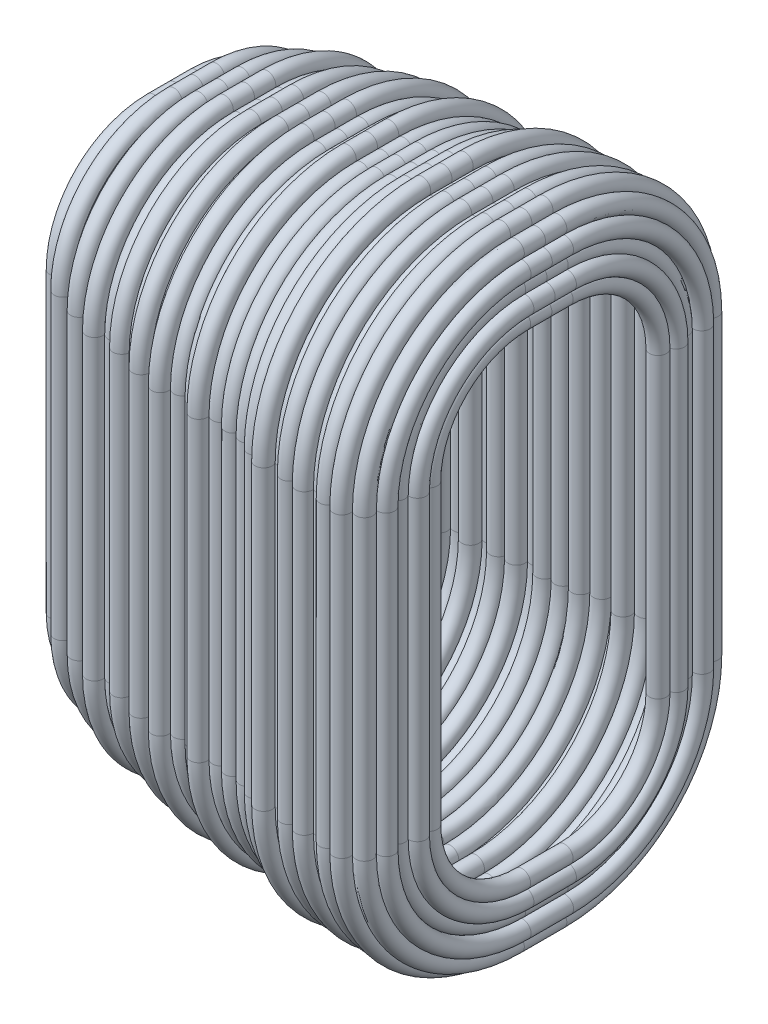
from build123d import *


with BuildPart() as part:
    # Barrer1: sweep along a path in Croquis1
    with BuildLine(Plane(origin=(0, 0, 0), x_dir=(0, 0, -1), z_dir=(1, 0, 0))) as barrer1_path:
        Line((-0.25, 2.55), (0.25, 2.55))
        ThreePointArc((0.25, 2.55), (0.815685425, 2.315685425), (1.05, 1.75))
        Line((1.05, 1.75), (1.05, -1.75))
        ThreePointArc((1.05, -1.75), (0.815685425, -2.315685425), (0.25, -2.55))
        Line((0.25, -2.55), (-0.25, -2.55))
        ThreePointArc((-0.25, -2.55), (-0.815685425, -2.315685425), (-1.05, -1.75))
        Line((-1.05, -1.75), (-1.05, 1.75))
        ThreePointArc((-1.05, 1.75), (-0.815685425, 2.315685425), (-0.25, 2.55))
    # Croquis2 → Barrer1 (sweep)
    with BuildSketch(Plane.XY):
        with BuildLine():
            ThreePointArc((-2.168358999, 2.810721498), (-2.293450616, 2.701666902), (-2.145279967, 2.626925508))
            ThreePointArc((-2.145279967, 2.626925508), (-2.00206537, 2.488675521), (-2.115884149, 2.651981262))
            ThreePointArc((-2.115884149, 2.651981262), (-2.094230788, 2.714572804), (-2.116442681, 2.776968325))
            ThreePointArc((-2.116442681, 2.776968325), (-2.043783884, 2.785184688), (-1.996141742, 2.840655723))
            ThreePointArc((-1.996141742, 2.840655723), (-1.840039556, 2.796265073), (-1.847409239, 2.958388822))
            ThreePointArc((-1.847409239, 2.958388822), (-1.800657274, 2.972997965), (-1.766451452, 3.008056987))
            ThreePointArc((-1.766451452, 3.008056987), (-1.632539652, 2.921291995), (-1.585632666, 3.07380517))
            ThreePointArc((-1.585632666, 3.07380517), (-1.515452014, 3.073795574), (-1.462548178, 3.119909652))
            ThreePointArc((-1.462548178, 3.119909652), (-1.326912178, 3.031556502), (-1.284986756, 3.187907591))
            ThreePointArc((-1.284986756, 3.187907591), (-1.230944112, 3.185886052), (-1.183751847, 3.212297872))
            ThreePointArc((-1.183751847, 3.212297872), (-1.082680639, 3.090059437), (-0.990641083, 3.219235069))
            ThreePointArc((-0.990641083, 3.219235069), (-0.906566815, 3.196111267), (-0.836308297, 3.247753627))
            ThreePointArc((-0.836308297, 3.247753627), (-0.709225872, 3.156781549), (-0.648631696, 3.300844756))
            ThreePointArc((-0.648631696, 3.300844756), (-0.58323563, 3.290594778), (-0.525764362, 3.323439273))
            ThreePointArc((-0.525764362, 3.323439273), (-0.404715905, 3.2142119), (-0.341420805, 3.364468607))
            ThreePointArc((-0.341420805, 3.364468607), (-0.288510223, 3.359265806), (-0.240410905, 3.381916512))
            ThreePointArc((-0.240410905, 3.381916512), (-0.162710771, 3.26234603), (-0.044456194, 3.342034585))
            ThreePointArc((-0.044456194, 3.342034585), (0.085569109, 3.287089434), (0.140997905, 3.4169093))
            ThreePointArc((0.140997905, 3.4169093), (0.200954751, 3.402705221), (0.25785639, 3.426343804))
            ThreePointArc((0.25785639, 3.426343804), (0.334921236, 3.307268755), (0.453540083, 3.385033957))
            ThreePointArc((0.453540083, 3.385033957), (0.552592446, 3.341279753), (0.633405604, 3.41335634))
            ThreePointArc((0.633405604, 3.41335634), (0.751330258, 3.358801429), (0.823600044, 3.466780782))
            ThreePointArc((0.823600044, 3.466780782), (0.940020945, 3.441687637), (0.997887622, 3.545778654))
            ThreePointArc((0.997887622, 3.545778654), (1.052489374, 3.517501776), (1.113313954, 3.526518624))
            ThreePointArc((1.113313954, 3.526518624), (1.200440747, 3.37919275), (1.290388928, 3.524813202))
            ThreePointArc((1.290388928, 3.524813202), (1.394523226, 3.508426363), (1.455477998, 3.594432157))
            ThreePointArc((1.455477998, 3.594432157), (1.512862487, 3.529068305), (1.59973518, 3.533375056))
            ThreePointArc((1.59973518, 3.533375056), (1.692021184, 3.425750606), (1.799184117, 3.518572126))
            ThreePointArc((1.799184117, 3.518572126), (1.874502079, 3.526382707), (1.922753097, 3.584740568))
            ThreePointArc((1.922753097, 3.584740568), (1.993034437, 3.537521837), (2.074343916, 3.561140555))
            ThreePointArc((2.074343916, 3.561140555), (2.0938295, 3.466882407), (2.183816439, 3.432726333))
            ThreePointArc((2.183816439, 3.432726333), (2.150391968, 3.343546059), (2.206811777, 3.266818478))
            ThreePointArc((2.206811777, 3.266818478), (2.086721351, 3.174527912), (2.19565867, 3.069304722))
            ThreePointArc((2.19565867, 3.069304722), (2.184676162, 3.003257127), (2.217825502, 2.945084782))
            ThreePointArc((2.217825502, 2.945084782), (2.22202767, 2.751072709), (2.309411763, 2.924342334))
            ThreePointArc((2.309411763, 2.924342334), (2.381531029, 3.038585903), (2.27402465, 3.120409861))
            ThreePointArc((2.27402465, 3.120409861), (2.28173102, 3.199597068), (2.229195574, 3.259346786))
            ThreePointArc((2.229195574, 3.259346786), (2.349392911, 3.354046352), (2.235558255, 3.456306211))
            ThreePointArc((2.235558255, 3.456306211), (2.245250912, 3.597535132), (2.104003097, 3.606948449))
            ThreePointArc((2.104003097, 3.606948449), (2.038008411, 3.73185315), (1.912960411, 3.666130395))
            ThreePointArc((1.912960411, 3.666130395), (1.803867308, 3.711756098), (1.727534764, 3.62144357))
            ThreePointArc((1.727534764, 3.62144357), (1.688718417, 3.624901751), (1.651527701, 3.613260511))
            ThreePointArc((1.651527701, 3.613260511), (1.558857893, 3.720912704), (1.452028583, 3.62729547))
            ThreePointArc((1.452028583, 3.62729547), (1.319302795, 3.693722469), (1.266681323, 3.554943286))
            ThreePointArc((1.266681323, 3.554943286), (1.213948769, 3.578398112), (1.157037676, 3.568807564))
            ThreePointArc((1.157037676, 3.568807564), (1.086976961, 3.7144994), (0.969797781, 3.603127704))
            ThreePointArc((0.969797781, 3.603127704), (0.855341676, 3.622861541), (0.799425019, 3.521062956))
            ThreePointArc((0.799425019, 3.521062956), (0.701961791, 3.55255142), (0.62791956, 3.481781708))
            ThreePointArc((0.62791956, 3.481781708), (0.525652678, 3.539412387), (0.439074118, 3.460140935))
            ThreePointArc((0.439074118, 3.460140935), (0.3695891, 3.50412567), (0.290627618, 3.481149399))
            ThreePointArc((0.290627618, 3.481149399), (0.184614129, 3.60203641), (0.100041078, 3.465288729))
            ThreePointArc((0.100041078, 3.465288729), (0.007312491, 3.471106825), (-0.050179333, 3.398119626))
            ThreePointArc((-0.050179333, 3.398119626), (-0.119279715, 3.45753969), (-0.207887728, 3.436227093))
            ThreePointArc((-0.207887728, 3.436227093), (-0.322297889, 3.556390961), (-0.390552102, 3.405161326))
            ThreePointArc((-0.390552102, 3.405161326), (-0.450670194, 3.408843826), (-0.501998657, 3.377329786))
            ThreePointArc((-0.501998657, 3.377329786), (-0.620325537, 3.487123317), (-0.689136333, 3.341106386))
            ThreePointArc((-0.689136333, 3.341106386), (-0.765624381, 3.348654019), (-0.824875806, 3.299698356))
            ThreePointArc((-0.824875806, 3.299698356), (-0.942113133, 3.392925406), (-1.020367381, 3.265206392))
            ThreePointArc((-1.020367381, 3.265206392), (-1.08949567, 3.289942958), (-1.156885482, 3.260801384))
            ThreePointArc((-1.156885482, 3.260801384), (-1.276978286, 3.380514314), (-1.332054835, 3.220139625))
            ThreePointArc((-1.332054835, 3.220139625), (-1.399965168, 3.217729992), (-1.450656286, 3.172474825))
            ThreePointArc((-1.450656286, 3.172474825), (-1.583672784, 3.261789437), (-1.631608946, 3.108908395))
            ThreePointArc((-1.631608946, 3.108908395), (-1.700365438, 3.109439167), (-1.753211505, 3.065450191))
            ThreePointArc((-1.753211505, 3.065450191), (-1.90368865, 3.144407534), (-1.90764713, 2.974519443))
            ThreePointArc((-1.90764713, 2.974519443), (-1.962261695, 2.954555715), (-1.996535634, 2.907581272))
            ThreePointArc((-1.996535634, 2.907581272), (-2.139678536, 2.960676096), (-2.168358999, 2.810721498))
        make_face()
    sweep(path=barrer1_path.line)


solid = part.part
